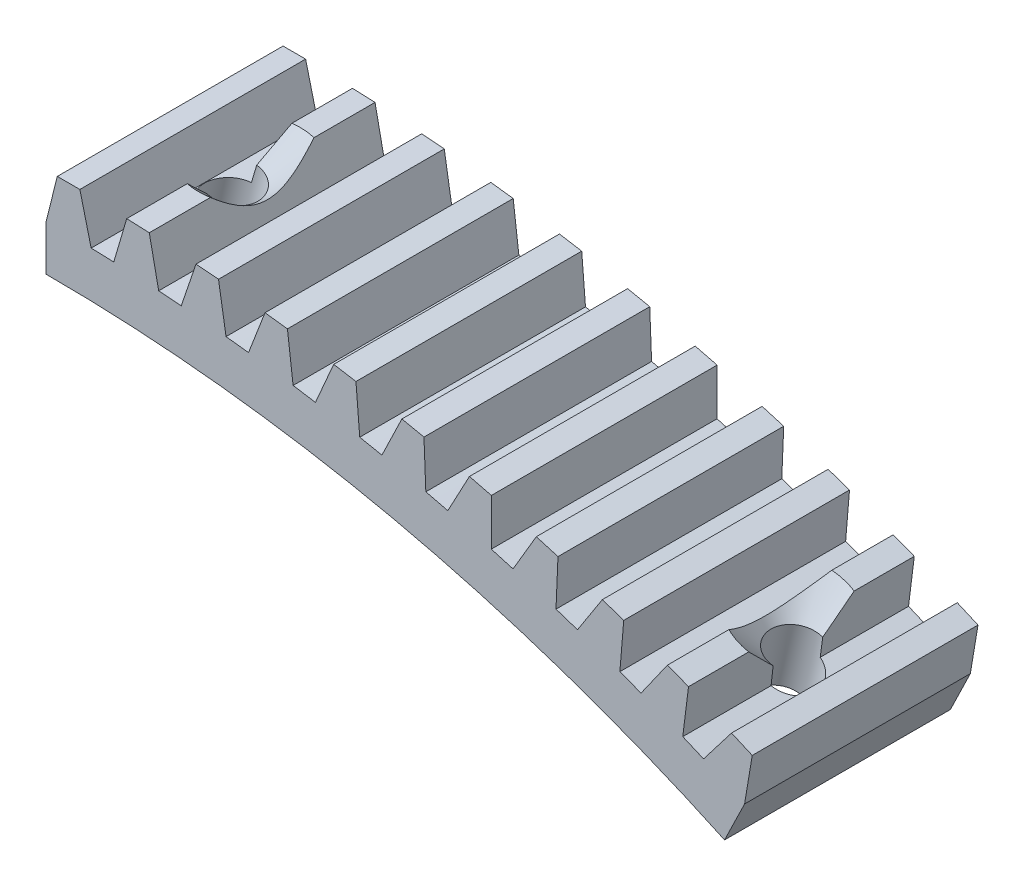
from build123d import *

# Parameters (mm, degrees)
BOSS_EXTRUDE1_DEPTH                                = 25.4
CIRPATTERN2_COUNT                                  = 11
CIRPATTERN2_ANGLE                                  = 23.5
CUT_EXTRUDE2_START                                 = -25.4
CUT_EXTRUDE2_DEPTH                                 = 25.4
CSK_FOR_10_FLAT_HEAD_MACHINE_SCREW_100_D           = 5.6134
CSK_FOR_10_FLAT_HEAD_MACHINE_SCREW_100_CSINK_D     = 12.7
CSK_FOR_10_FLAT_HEAD_MACHINE_SCREW_100_CSINK_ANGLE = 90


with BuildPart() as part:
    # Sketch1 → Boss-Extrude1 (new body)
    with BuildSketch(Plane.XY):
        with BuildLine():
            Line((1.27, 190.5), (0, 185.42))
            Line((0, 185.42), (0, 180.34))
            ThreePointArc((0, 180.34), (3.828563565, 180.299355798), (7.655401402, 180.177441511))
            Line((7.655401402, 180.177441511), (7.874, 185.32237567))
            ThreePointArc((7.874, 185.32237567), (6.477183927, 185.376451817), (5.08, 185.42))
            Line((5.08, 185.42), (3.81, 190.5))
            Line((3.81, 190.5), (1.27, 190.5))
        make_face()
    boss_extrude1 = extrude(amount=BOSS_EXTRUDE1_DEPTH)

    # CirPattern2: Boss-Extrude1 ×11 about axis
    cirpattern2_axis = Axis((0, 0, 26.67), (0, 0, -1))
    for i in range(1, CIRPATTERN2_COUNT):
        add(boss_extrude1.rotate(cirpattern2_axis, i * CIRPATTERN2_ANGLE / (CIRPATTERN2_COUNT - 1)))

    # Sketch4 → Cut-Extrude2 (cut)
    with BuildSketch(Plane.XY.offset(25.4).offset(CUT_EXTRUDE2_START)):
        with BuildLine():
            Line((78.866050023, 162.180953733), (81.118055775, 166.812001449))
            ThreePointArc((81.118055775, 166.812001449), (79.858654337, 167.418571633), (78.594717538, 168.015633722))
            Line((78.594717538, 168.015633722), (76.34244866, 163.384044914))
            ThreePointArc((76.34244866, 163.384044914), (77.606580732, 162.787389644), (78.866050023, 162.180953733))
        make_face()
    extrude(amount=CUT_EXTRUDE2_DEPTH, mode=Mode.SUBTRACT)

    # CSK for _10 Flat Head Machine Screw _100 (through all)
    with Locations(Plane(origin=(40.80368391, 183.714401712, 0), x_dir=(-0.9762115157391993, 0.2168203785122032, 0), z_dir=(0.21682037851220323, 0.9762115157391994, -6.9829626776862675e-15))):
        with Locations((-32.344274852, 12.7), (32.394112766, 12.7)):
            CounterSinkHole(CSK_FOR_10_FLAT_HEAD_MACHINE_SCREW_100_D / 2, CSK_FOR_10_FLAT_HEAD_MACHINE_SCREW_100_CSINK_D / 2, counter_sink_angle=CSK_FOR_10_FLAT_HEAD_MACHINE_SCREW_100_CSINK_ANGLE)


solid = part.part
